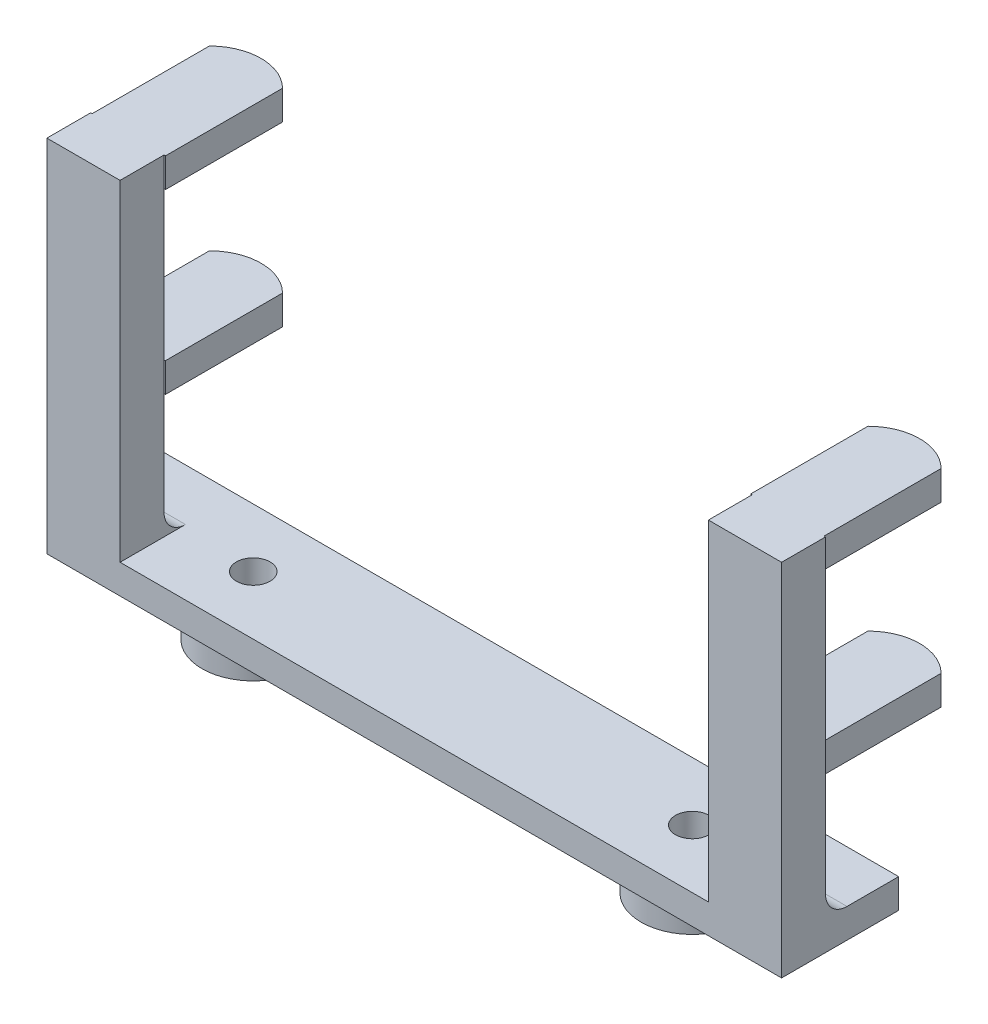
from build123d import *

# Parameters (mm, degrees)
BOSS_EXTRUDE1_DEPTH  = 10.16
CUT_EXTRUDE1_DEPTH   = 64.754
SKETCH3_R            = 1.4605
CUT_EXTRUDE2_DEPTH   = 6.35
BOSS_EXTRUDE2_DEPTH  = 2.54
MIRROR2_COPY_1_DEPTH = 2.54
SKETCH6_R            = 4.445
SKETCH6_R_2          = 1.4605
BOSS_EXTRUDE3_DEPTH  = 2.54


with BuildPart() as part:
    # Sketch1 → Boss-Extrude1 (new body)
    with BuildSketch(Plane.XY):
        Polygon((25.527, 0), (-25.527, 0), (-25.527, 28.702), (-31.877, 28.702), (-31.877, -2.54), (31.877, -2.54), (31.877, 28.702), (25.527, 28.702), align=None)
    extrude(amount=BOSS_EXTRUDE1_DEPTH)

    # Sketch2 → Cut-Extrude1 (cut, through all)
    with BuildSketch(Plane(origin=(31.877, 0, 0), x_dir=(0, 0, -1), z_dir=(1, 0, 0))):
        with BuildLine():
            Line((-6.35, 28.702), (-6.35, 1.867416652))
            ThreePointArc((-6.35, 1.867416652), (-5.803046326, 0.546953674), (-4.482583348, 0))
            Line((-4.482583348, 0), (0, 0))
            Line((0, 0), (0, 28.702))
            Line((0, 28.702), (-6.35, 28.702))
        make_face()
    extrude(amount=-CUT_EXTRUDE1_DEPTH, mode=Mode.SUBTRACT)

    # Sketch3 → Cut-Extrude2 (cut)
    with BuildSketch(Plane.XZ.offset(2.54)):
        with Locations((-19.05, 5.08)):
            Circle(SKETCH3_R)
        with Locations((19.05, 5.08)):
            Circle(SKETCH3_R)
    extrude(amount=-CUT_EXTRUDE2_DEPTH, mode=Mode.SUBTRACT)

    # Sketch5 → Boss-Extrude2 (add)
    with BuildSketch(Plane(origin=(0, 28.702, 0), x_dir=(1, 0, 0), z_dir=(0, 1, 0))):
        with BuildLine():
            Line((-31.75, -6.35), (-31.75, 3.81))
            ThreePointArc((-31.75, 3.81), (-28.575, 5.125128061), (-25.4, 3.81))
            Line((-25.4, 3.81), (-25.4, -6.35))
            Line((-25.4, -6.35), (-31.75, -6.35))
        make_face()
    boss_extrude2 = extrude(amount=-BOSS_EXTRUDE2_DEPTH)

    # Mirror1: Boss-Extrude2 across plane
    add(boss_extrude2.mirror(Plane(origin=(0, 19.7358, 0), x_dir=(0, 0, 1), z_dir=(0, -1, 0))))

    # Mirror2: Boss-Extrude2 across plane
    add(boss_extrude2.mirror(Plane(origin=(0, 0, 0), x_dir=(0, 0, 1), z_dir=(1, 0, 0))))

    # Mirror2 copy 1 sketch → Mirror2 copy 1 (add)
    with BuildSketch(Plane(origin=(0, 10.7696, 0), x_dir=(-1, 0, 0), z_dir=(0, -1, 0))):
        with BuildLine():
            Line((-31.75, -6.35), (-31.75, 3.81))
            ThreePointArc((-31.75, 3.81), (-28.575, 5.125128061), (-25.4, 3.81))
            Line((-25.4, 3.81), (-25.4, -6.35))
            Line((-25.4, -6.35), (-31.75, -6.35))
        make_face()
    extrude(amount=-MIRROR2_COPY_1_DEPTH)

    # Sketch6 → Boss-Extrude3 (add)
    with BuildSketch(Plane.XZ.offset(2.54)):
        with Locations((-19.05, 5.08)):
            Circle(SKETCH6_R)
        with Locations((-19.05, 5.08)):
            Circle(SKETCH6_R_2, mode=Mode.SUBTRACT)
        with Locations((19.05, 5.08)):
            Circle(SKETCH6_R)
        with Locations((19.05, 5.08)):
            Circle(SKETCH6_R_2, mode=Mode.SUBTRACT)
    extrude(amount=BOSS_EXTRUDE3_DEPTH)


solid = part.part
